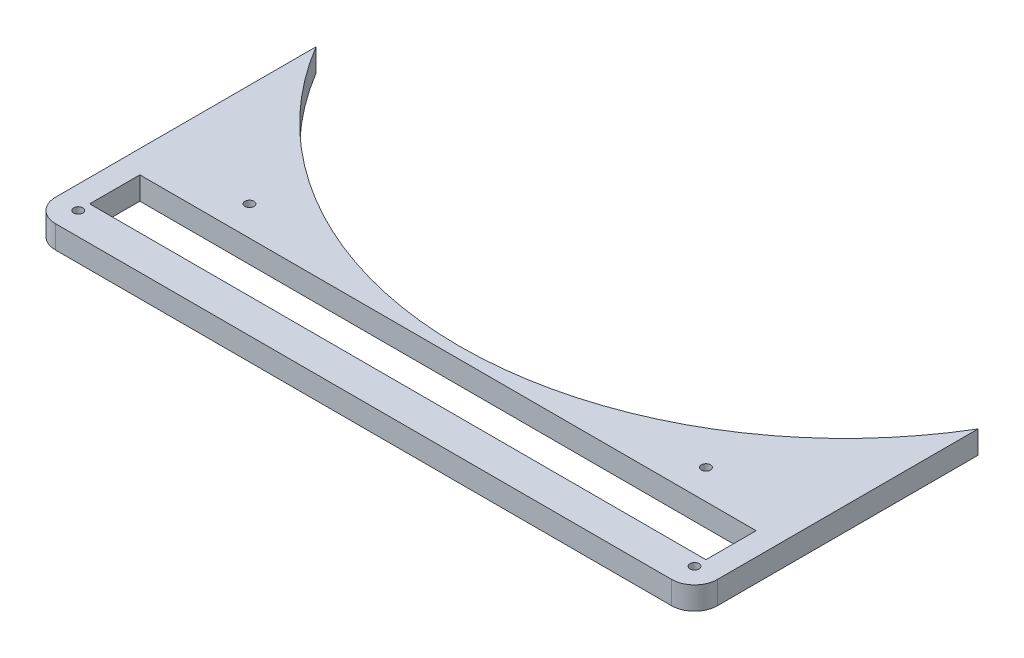
from build123d import *

# Parameters (mm, degrees)
BOSS_EXTRU_1_DEPTH      = 10
ESQUISSE3_R             = 2
ENL_V_MAT_EXTRU_1_DEPTH = 10
CONG_1_R                = 10
ESQUISSE4_R             = 32.5
ENL_V_MAT_EXTRU_2_DEPTH = 10
ESQUISSE5_R             = 2
ENL_V_MAT_EXTRU_3_DEPTH = 10
ESQUISSE6_W             = 270
ESQUISSE6_H             = 22
ENL_V_MAT_EXTRU_4_DEPTH = 10
ESQUISSE7_R             = 2
ENL_V_MAT_EXTRU_5_DEPTH = 10
ENL_V_MAT_EXTRU_6_DEPTH = 10
ESQUISSE9_R             = 2
ENL_V_MAT_EXTRU_7_DEPTH = 10
ESQUISSE10_R            = 6
ENL_V_MAT_EXTRU_8_DEPTH = 5


with BuildPart() as part:
    # Esquisse2 → Boss.-Extru.1 (new body)
    with BuildSketch(Plane(origin=(0, 0, 0), x_dir=(1, 0, 0), z_dir=(0, 1, 0))):
        Polygon((0, 0), (290, 0), (290, 180), (275, 180), (225, 130), (65, 130), (15, 180), (0, 180), align=None)
    extrude(amount=BOSS_EXTRU_1_DEPTH)

    # Esquisse3 → Enlèv. mat.-Extru.1 (cut)
    with BuildSketch(Plane(origin=(0, 10, 0), x_dir=(1, 0, 0), z_dir=(0, 1, 0))):
        with Locations((10, 10)):
            Circle(ESQUISSE3_R)
        with Locations((280, 10)):
            Circle(ESQUISSE3_R)
    extrude(amount=-ENL_V_MAT_EXTRU_1_DEPTH, mode=Mode.SUBTRACT)

    # Congé1
    cong_1_edges = [part.edges().sort_by_distance(p)[0] for p in [
        (290, 5, 0),
        (0, 5, 0),
    ]]
    fillet(cong_1_edges, radius=CONG_1_R)

    # Esquisse4 → Enlèv. mat.-Extru.2 (cut)
    with BuildSketch(Plane.XZ):
        with Locations((239.106279441, -116.309672248)):
            Circle(ESQUISSE4_R)
        with Locations((179.153264776, -81.942630954)):
            Circle(ESQUISSE4_R)
        with Locations((110.048910395, -82.156407472)):
            Circle(ESQUISSE4_R)
        with Locations((50.309672248, -116.893720559)):
            Circle(ESQUISSE4_R)
    extrude(amount=-ENL_V_MAT_EXTRU_2_DEPTH, mode=Mode.SUBTRACT)

    # Esquisse5 → Enlèv. mat.-Extru.3 (cut)
    with BuildSketch(Plane(origin=(0, 0, 0), x_dir=(-1, 0, 0), z_dir=(0, -1, 0))):
        with Locations((-144.50570114, 101.001110603)):
            Circle(ESQUISSE5_R)
        with Locations((-199.571369329, 115.491017964)):
            Circle(ESQUISSE5_R)
        with Locations((-221.896020418, 76.419161677)):
            Circle(ESQUISSE5_R)
        with Locations((-66.897585359, 77.115673706)):
            Circle(ESQUISSE5_R)
        with Locations((-89.572479932, 115.985316824)):
            Circle(ESQUISSE5_R)
    extrude(amount=-ENL_V_MAT_EXTRU_3_DEPTH, mode=Mode.SUBTRACT)

    # Esquisse6 → Enlèv. mat.-Extru.4 (cut)
    with BuildSketch(Plane(origin=(0, 10, 0), x_dir=(1, 0, 0), z_dir=(0, 1, 0))):
        with Locations((145, 26)):
            Rectangle(ESQUISSE6_W, ESQUISSE6_H)
    extrude(amount=-ENL_V_MAT_EXTRU_4_DEPTH, mode=Mode.SUBTRACT)

    # Esquisse7 → Enlèv. mat.-Extru.5 (cut)
    with BuildSketch(Plane(origin=(0, 10, 0), x_dir=(1, 0, 0), z_dir=(0, 1, 0))):
        with Locations((10, 165)):
            Circle(ESQUISSE7_R)
        with Locations((280, 165)):
            Circle(ESQUISSE7_R)
    extrude(amount=-ENL_V_MAT_EXTRU_5_DEPTH, mode=Mode.SUBTRACT)

    # Esquisse8 → Enlèv. mat.-Extru.6 (cut)
    with BuildSketch(Plane.XZ):
        with BuildLine():
            Line((290, -124.189862343), (307.144293733, -133.59002346))
            Line((307.144293733, -133.59002346), (298.572146866, -188.47958085))
            Line((298.572146866, -188.47958085), (-31.012454314, -192.613510827))
            Line((-31.012454314, -192.613510827), (-21.06069283, -128.889942902))
            Line((-21.06069283, -128.889942902), (0, -124.189862343))
            ThreePointArc((0, -124.189862343), (145, -42), (290, -124.189862343))
        make_face()
    extrude(amount=-ENL_V_MAT_EXTRU_6_DEPTH, mode=Mode.SUBTRACT)

    # Esquisse9 → Enlèv. mat.-Extru.7 (cut)
    with BuildSketch(Plane(origin=(0, 10, 0), x_dir=(1, 0, 0), z_dir=(0, 1, 0))):
        with Locations((45, 50)):
            Circle(ESQUISSE9_R)
        with Locations((245, 50)):
            Circle(ESQUISSE9_R)
    extrude(amount=-ENL_V_MAT_EXTRU_7_DEPTH, mode=Mode.SUBTRACT)

    # Esquisse10 → Enlèv. mat.-Extru.8 (cut)
    with BuildSketch(Plane.XZ):
        with Locations((10, -10)):
            Circle(ESQUISSE10_R)
        with Locations((45, -50)):
            Circle(ESQUISSE10_R)
        with Locations((245, -50)):
            Circle(ESQUISSE10_R)
        with Locations((280, -10)):
            Circle(ESQUISSE10_R)
    extrude(amount=-ENL_V_MAT_EXTRU_8_DEPTH, mode=Mode.SUBTRACT)


solid = part.part
